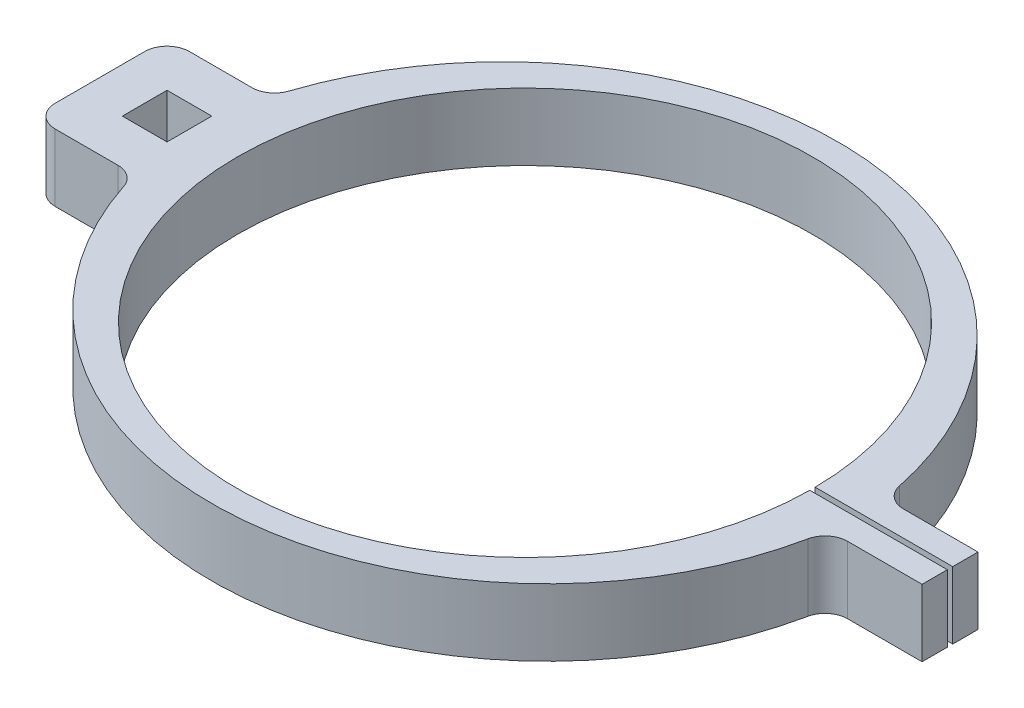
from build123d import *

# Parameters (mm, degrees)
SKETCH1_W           = 6.35
SKETCH1_H           = 6.35
BOSS_EXTRUDE1_DEPTH = 4.7625
FILLET1_R           = 3.175


with BuildPart() as part:
    # Sketch1 → Boss-Extrude1 (new body, symmetric)
    with BuildSketch(Plane(origin=(0, 0, 0), x_dir=(1, 0, 0), z_dir=(0, 1, 0))):
        with BuildLine():
            Line((40.80332125, -0.381), (60.325, -0.381))
            Line((60.325, -0.381), (60.325, -3.96875))
            Line((60.325, -3.96875), (47.086170591, -3.96875))
            ThreePointArc((47.086170591, -3.96875), (2.8406806, -44.365205708), (-45.900442536, -9.525))
            Line((-45.900442536, -9.525), (-60.325, -9.525))
            Line((-60.325, -9.525), (-60.325, 9.525))
            Line((-60.325, 9.525), (-45.900442536, 9.525))
            ThreePointArc((-45.900442536, 9.525), (2.8406806, 44.365205708), (47.086170591, 3.96875))
            Line((47.086170591, 3.96875), (60.325, 3.96875))
            Line((60.325, 3.96875), (60.325, 0.381))
            Line((60.325, 0.381), (40.80332125, 0.381))
            ThreePointArc((40.80332125, 0.381), (-40.8051, 0), (40.80332125, -0.381))
        make_face()
        with Locations((-50.8, 0)):
            Rectangle(SKETCH1_W, SKETCH1_H, mode=Mode.SUBTRACT)
    extrude(amount=BOSS_EXTRUDE1_DEPTH, both=True)

    # Fillet1
    fillet1_edges = [part.edges().sort_by_distance(p)[0] for p in [
        (-45.900442536, 0, 9.525),
        (-60.325, 0, 9.525),
        (-60.325, 0, -9.525),
        (-45.900442536, 0, -9.525),
        (47.086170591, 0, -3.96875),
        (47.086170591, 0, 3.96875),
    ]]
    fillet(fillet1_edges, radius=FILLET1_R)


solid = part.part
